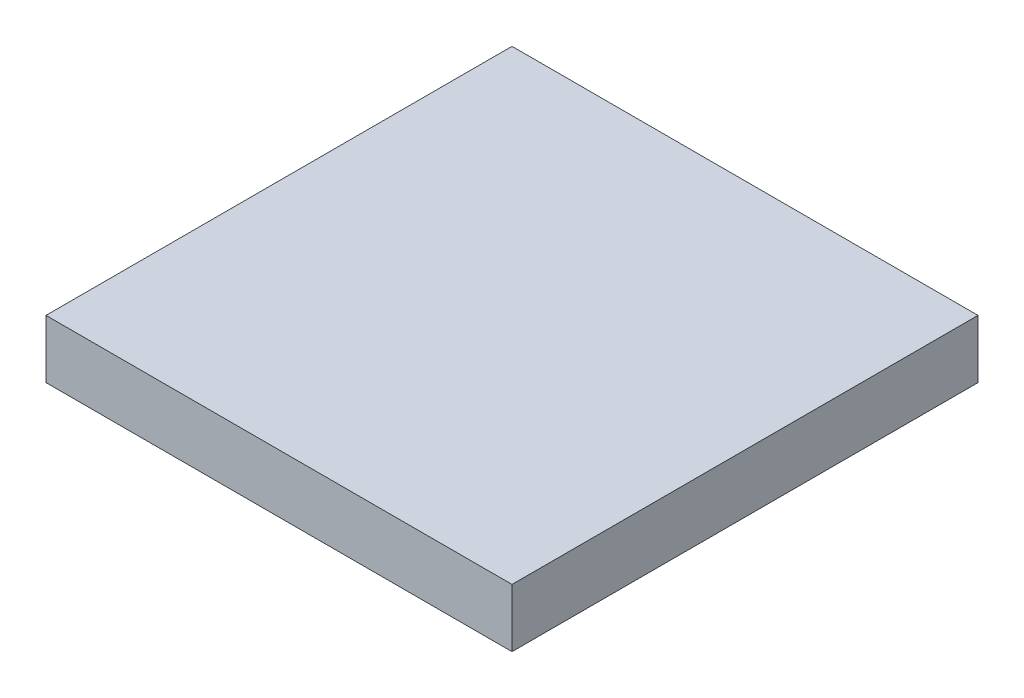
from build123d import *

# Parameters (mm, degrees)
SKETCH1_W           = 0.4
SKETCH1_H           = 0.4
BOSS_EXTRUDE1_DEPTH = 0.05


with BuildPart() as part:
    # Sketch1 → Boss-Extrude1 (new body)
    with BuildSketch(Plane(origin=(0, 0, 0), x_dir=(1, 0, 0), z_dir=(0, 1, 0))):
        Rectangle(SKETCH1_W, SKETCH1_H)
    extrude(amount=BOSS_EXTRUDE1_DEPTH)


solid = part.part
